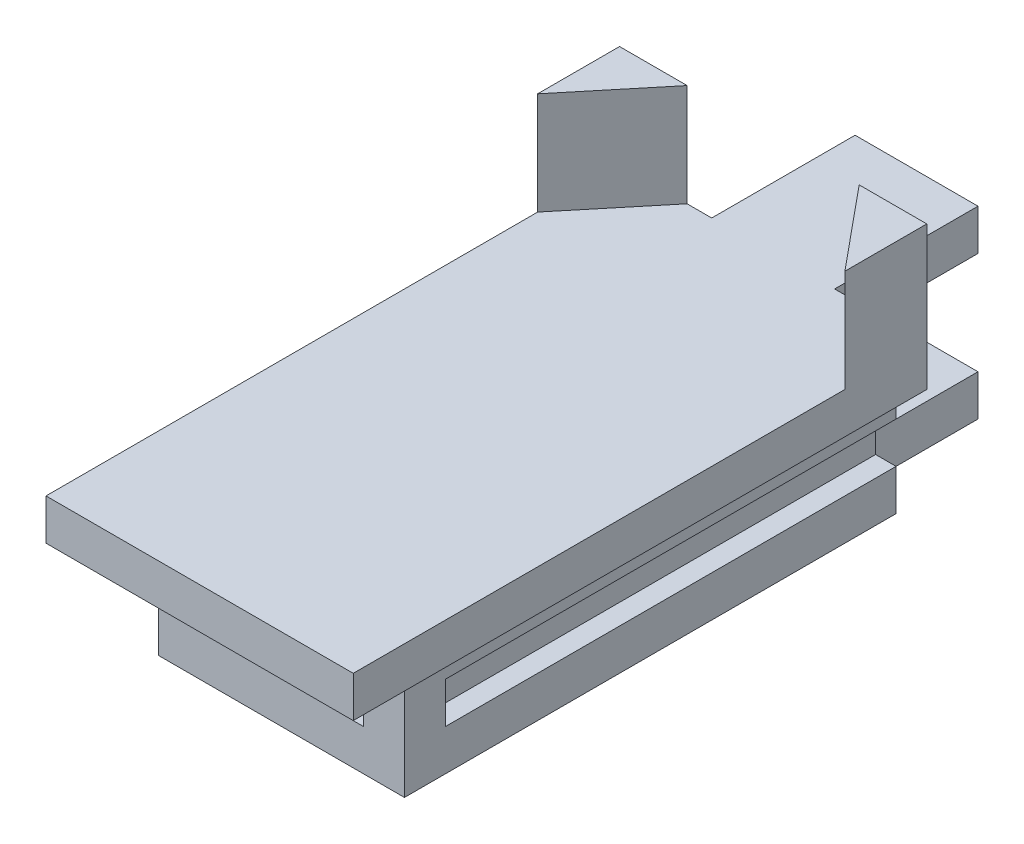
from build123d import *

# Parameters (mm, degrees)
SKETCH1_W            = 7.5
SKETCH1_H            = 10
BOSS_EXTRUDE1_DEPTH  = 1
BOSS_EXTRUDE2_DEPTH  = 2.5
SKETCH10_W           = 7.5
SKETCH10_H           = 1
BOSS_EXTRUDE5_DEPTH  = 2
SKETCH56_W           = 7.5
SKETCH56_H           = 1
BOSS_EXTRUDE17_DEPTH = 2
SKETCH57_W           = 3
SKETCH57_H           = 1
BOSS_EXTRUDE18_DEPTH = 5
SKETCH58_W           = 1.5
SKETCH58_H           = 1
BOSS_EXTRUDE19_DEPTH = 2
SKETCH59_W           = 1.5
SKETCH59_H           = 1
BOSS_EXTRUDE20_DEPTH = 2
SKETCH60_W           = 1
SKETCH60_H           = 1.5
BOSS_EXTRUDE23_DEPTH = 1.5
SKETCH61_W           = 1
SKETCH61_H           = 0.75
CUT_EXTRUDE1_DEPTH   = 0.5
SKETCH62_W           = 6
SKETCH62_H           = 12
BOSS_EXTRUDE25_DEPTH = 3
SKETCH64_W           = 4
SKETCH64_H           = 2
CUT_EXTRUDE2_DEPTH   = 12
SKETCH65_W           = 4
SKETCH65_H           = 1
BOSS_EXTRUDE26_DEPTH = 3
SKETCH66_R           = 1
CUT_EXTRUDE3_DEPTH   = 1
SKETCH68_W           = 6
SKETCH68_H           = 1
SKETCH68_W_2         = 3
SKETCH68_W_3         = 2
CUT_EXTRUDE6_DEPTH   = 0.5
SKETCH67_W           = 6
SKETCH67_H           = 1
SKETCH67_W_2         = 3
SKETCH67_W_3         = 2
CUT_EXTRUDE7_DEPTH   = 0.5
SKETCH69_W           = 7
SKETCH69_H           = 1.5
CUT_EXTRUDE8_DEPTH   = 10


with BuildPart() as part:
    # Sketch1 → Boss-Extrude1 (new body)
    with BuildSketch(Plane(origin=(0, 0, 0), x_dir=(1, 0, 0), z_dir=(0, 1, 0))):
        Rectangle(SKETCH1_W, SKETCH1_H)
    extrude(amount=BOSS_EXTRUDE1_DEPTH)

    # Sketch2 → Boss-Extrude2 (add)
    with BuildSketch(Plane(origin=(0, 1, 0), x_dir=(1, 0, 0), z_dir=(0, 1, 0))):
        Polygon((-3.75, 3), (-2.1, 5), (-3.75, 5), align=None)
        Polygon((3.75, 5), (2.1, 5), (3.75, 3), align=None)
    extrude(amount=BOSS_EXTRUDE2_DEPTH)

    # Sketch10 → Boss-Extrude5 (add)
    with BuildSketch(Plane.XY.offset(5)):
        with Locations((0, 0.5)):
            Rectangle(SKETCH10_W, SKETCH10_H)
    extrude(amount=BOSS_EXTRUDE5_DEPTH)

    # Sketch56 → Boss-Extrude17 (add)
    with BuildSketch(Plane.XY.offset(7)):
        with Locations((0, 0.5)):
            Rectangle(SKETCH56_W, SKETCH56_H)
    extrude(amount=BOSS_EXTRUDE17_DEPTH)

    # Sketch57 → Boss-Extrude18 (add)
    with BuildSketch(Plane(origin=(0, 0, -5), x_dir=(-1, 0, 0), z_dir=(0, 0, -1))):
        with Locations((0, 0.5)):
            Rectangle(SKETCH57_W, SKETCH57_H)
    extrude(amount=BOSS_EXTRUDE18_DEPTH)

    # Sketch58 → Boss-Extrude19 (add)
    with BuildSketch(Plane(origin=(1.5, 0, 0), x_dir=(0, 0, -1), z_dir=(1, 0, 0))):
        with Locations((9.25, 0.5)):
            Rectangle(SKETCH58_W, SKETCH58_H)
    extrude(amount=BOSS_EXTRUDE19_DEPTH)

    # Sketch59 → Boss-Extrude20 (add)
    with BuildSketch(Plane.ZY.offset(1.5)):
        with Locations((-9.25, 0.5)):
            Rectangle(SKETCH59_W, SKETCH59_H)
    extrude(amount=BOSS_EXTRUDE20_DEPTH)

    # Sketch60 → Boss-Extrude23 (add)
    with BuildSketch(Plane(origin=(0, 1, 0), x_dir=(1, 0, 0), z_dir=(0, 1, 0))):
        with Locations((3, 9.25)):
            Rectangle(SKETCH60_W, SKETCH60_H)
        with Locations((-3, 9.25)):
            Rectangle(SKETCH60_W, SKETCH60_H)
    extrude(amount=BOSS_EXTRUDE23_DEPTH)

    # Sketch61 → Cut-Extrude1 (cut)
    with BuildSketch(Plane(origin=(0, 2.5, 0), x_dir=(1, 0, 0), z_dir=(0, 1, 0))):
        with Locations((-3, 9.245443114)):
            Rectangle(SKETCH61_W, SKETCH61_H)
        with Locations((3, 9.245443114)):
            Rectangle(SKETCH61_W, SKETCH61_H)
    extrude(amount=-CUT_EXTRUDE1_DEPTH, mode=Mode.SUBTRACT)

    # Sketch62 → Boss-Extrude25 (add)
    with BuildSketch(Plane(origin=(0, 0, 0), x_dir=(-1, 0, 0), z_dir=(0, -1, 0))):
        with Locations((0, -1)):
            Rectangle(SKETCH62_W, SKETCH62_H)
    extrude(amount=BOSS_EXTRUDE25_DEPTH)

    # Sketch64 → Cut-Extrude2 (cut)
    with BuildSketch(Plane.XY.offset(7)):
        with Locations((0, -1)):
            Rectangle(SKETCH64_W, SKETCH64_H)
    extrude(amount=-CUT_EXTRUDE2_DEPTH, mode=Mode.SUBTRACT)

    # Sketch65 → Boss-Extrude26 (add)
    with BuildSketch(Plane(origin=(0, 0, -5), x_dir=(-1, 0, 0), z_dir=(0, 0, -1))):
        with Locations((0, -2.5)):
            Rectangle(SKETCH65_W, SKETCH65_H)
    extrude(amount=BOSS_EXTRUDE26_DEPTH)

    # Sketch66 → Cut-Extrude3 (cut)
    with BuildSketch(Plane(origin=(0, -3, 0), x_dir=(-1, 0, 0), z_dir=(0, -1, 0))):
        with Locations(Location((0, -5, 0), (0, 0, 90))):  # turned: the seam where the file's is
            Circle(SKETCH66_R)
        with Locations(Location((0, 5, 0), (0, 0, 90))):  # turned: the seam where the file's is
            Circle(SKETCH66_R)
    extrude(amount=-CUT_EXTRUDE3_DEPTH, mode=Mode.SUBTRACT)

    # Sketch68 → Cut-Extrude6 (cut)
    with BuildSketch(Plane(origin=(3, 0, 0), x_dir=(0, 0, -1), z_dir=(1, 0, 0))):
        with Locations((-3, -1.5)):
            Rectangle(SKETCH68_W, SKETCH68_H)
        with Locations((1.5, -1.5)):
            Rectangle(SKETCH68_W_2, SKETCH68_H)
        with Locations((4, -1.5)):
            Rectangle(SKETCH68_W_3, SKETCH68_H)
    extrude(amount=-CUT_EXTRUDE6_DEPTH, mode=Mode.SUBTRACT)

    # Sketch67 → Cut-Extrude7 (cut)
    with BuildSketch(Plane.ZY.offset(3)):
        with Locations((3, -1.5)):
            Rectangle(SKETCH67_W, SKETCH67_H)
        with Locations((-1.5, -1.5)):
            Rectangle(SKETCH67_W_2, SKETCH67_H)
        with Locations((-4, -1.5)):
            Rectangle(SKETCH67_W_3, SKETCH67_H)
    extrude(amount=-CUT_EXTRUDE7_DEPTH, mode=Mode.SUBTRACT)

    # Sketch69 → Cut-Extrude8 (cut)
    with BuildSketch(Plane.XZ):
        with Locations((0, -9.25)):
            Rectangle(SKETCH69_W, SKETCH69_H)
    extrude(amount=-CUT_EXTRUDE8_DEPTH, mode=Mode.SUBTRACT)


solid = part.part
